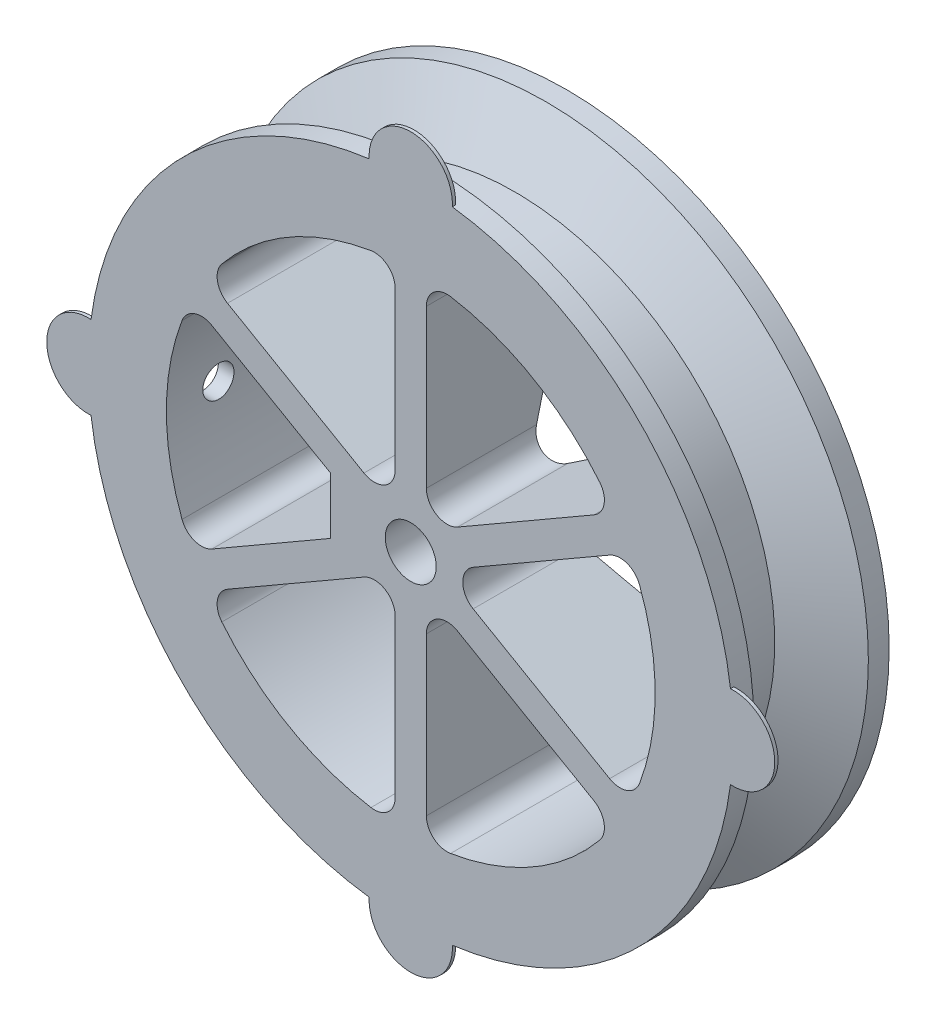
from build123d import *

# Parameters (mm, degrees)
SKETCH4_R                 = 3.1115
CUT_EXTRUDE1_DEPTH        = 20.05
CUT_EXTRUDE2_DEPTH        = 20.05
CIRPATTERN1_COUNT         = 6
SKETCH6_W                 = 5.08
SKETCH6_H                 = 6.929069256
BOSS_EXTRUDE2_DEPTH       = 19.05
F_4_CLEARANCE_HOLE1_D     = 3.4544
F_4_CLEARANCE_HOLE1_DEPTH = 12.7
F_4_CLEARANCE_HOLE1_TIP   = 1.037806461
SKETCH10_R                = 1.905
CUT_EXTRUDE3_DEPTH        = 30.55925
CUT_EXTRUDE7_START        = -1.778
CUT_EXTRUDE7_DEPTH        = 2.413
SKETCH14_R                = 5.08
PRINT_TABS_DEPTH          = 0.4


with BuildPart() as part:
    # Sketch2 → Revolve1 (revolve)
    with BuildSketch(Plane(origin=(0, 0, 0), x_dir=(1, 0, 0), z_dir=(0, 1, 0))):
        Polygon((0, 9.525), (39.37, 9.525), (39.37, 6.985), (31.75, 3.175), (31.75, -6.985), (39.37, -6.985), (39.37, -9.525), (0, -9.525), align=None)
    revolve(axis=Axis((0, 0, -9.525), (0, 0, 1)))

    # Sketch4 → Cut-Extrude1 (cut, through all)
    with BuildSketch(Plane.XY.offset(9.525)):
        Circle(SKETCH4_R)
    extrude(amount=-CUT_EXTRUDE1_DEPTH, mode=Mode.SUBTRACT)

    # Sketch5 → Cut-Extrude2 (cut, through all)
    with BuildSketch(Plane.XY.offset(9.525)):
        with BuildLine():
            Line((5.715, 5.499261314), (22.3788898, 15.120162576))
            ThreePointArc((22.3788898, 15.120162576), (23.607834508, 16.865031588), (23.072507456, 18.931017529))
            ThreePointArc((23.072507456, 18.931017529), (14.9225, 25.846528176), (4.858488372, 29.44688635))
            ThreePointArc((4.858488372, 29.44688635), (2.801628536, 28.877500206), (1.905, 26.940768363))
            Line((1.905, 26.940768363), (1.905, 7.69896584))
            ThreePointArc((1.905, 7.69896584), (3.175, 5.499261314), (5.715, 5.499261314))
        make_face()
    cut_extrude2 = extrude(amount=-CUT_EXTRUDE2_DEPTH, mode=Mode.SUBTRACT)

    # CirPattern1: Cut-Extrude2 ×6 about axis
    cirpattern1_axis = Axis((0, 0, 0), (0, 0, 1))
    for i in range(1, CIRPATTERN1_COUNT):
        add(cut_extrude2.rotate(cirpattern1_axis, i * 360 / CIRPATTERN1_COUNT), mode=Mode.SUBTRACT)

    # Sketch6 → Boss-Extrude2 (add, through all)
    with BuildSketch(Plane.XY.offset(9.525)):
        with Locations((-7.27075, 0)):
            Rectangle(SKETCH6_W, SKETCH6_H)
    extrude(amount=-BOSS_EXTRUDE2_DEPTH)

    # 4 Clearance Hole1
    with Locations(Plane.ZY.offset(9.81075)):
        with Locations((3.175, 0)):
            Hole(F_4_CLEARANCE_HOLE1_D / 2, depth=F_4_CLEARANCE_HOLE1_DEPTH)
            with Locations((0, 0, -(F_4_CLEARANCE_HOLE1_DEPTH + F_4_CLEARANCE_HOLE1_TIP / 2))):  # 118° drill point
                Cone(0, F_4_CLEARANCE_HOLE1_D / 2, F_4_CLEARANCE_HOLE1_TIP, mode=Mode.SUBTRACT)

    # Sketch10 → Cut-Extrude3 (cut, through all)
    with BuildSketch(Plane.ZY.offset(9.81075)):
        with Locations((3.175, 0)):
            Circle(SKETCH10_R)
    extrude(amount=CUT_EXTRUDE3_DEPTH, mode=Mode.SUBTRACT)

    # Sketch15 → Cut-Extrude7 (cut)
    with BuildSketch(Plane.ZY.offset(9.81075).offset(CUT_EXTRUDE7_START)):
        Polygon((-9.525, -3.429), (5.154734073, -3.429), (7.134468146, 0), (5.154734073, 3.429), (-9.525, 3.429), align=None)
    extrude(amount=-CUT_EXTRUDE7_DEPTH, mode=Mode.SUBTRACT)

    # Sketch16 → Cut-Revolve1 (revolve, cut)
    with BuildSketch(Plane(origin=(0, 0, 0), x_dir=(1, 0, 0), z_dir=(0, 1, 0))):
        Polygon((0, 1.905), (29.845, 9.525), (0, 9.525), align=None)
    revolve(axis=Axis((0, 0, 9.525), (0, 0, -1)), mode=Mode.SUBTRACT)

    # Sketch14 → Print Tabs (add)
    with BuildSketch(Plane(origin=(0, 0, 9.525), x_dir=(-1, 0, 0), z_dir=(0, 0, -1))):
        with Locations((39.37, 0)):
            Circle(SKETCH14_R)
        with Locations((0, -39.37)):
            Circle(SKETCH14_R)
        with Locations((-39.37, 0)):
            Circle(SKETCH14_R)
        with Locations((0, 39.37)):
            Circle(SKETCH14_R)
    extrude(amount=PRINT_TABS_DEPTH)


solid = part.part
